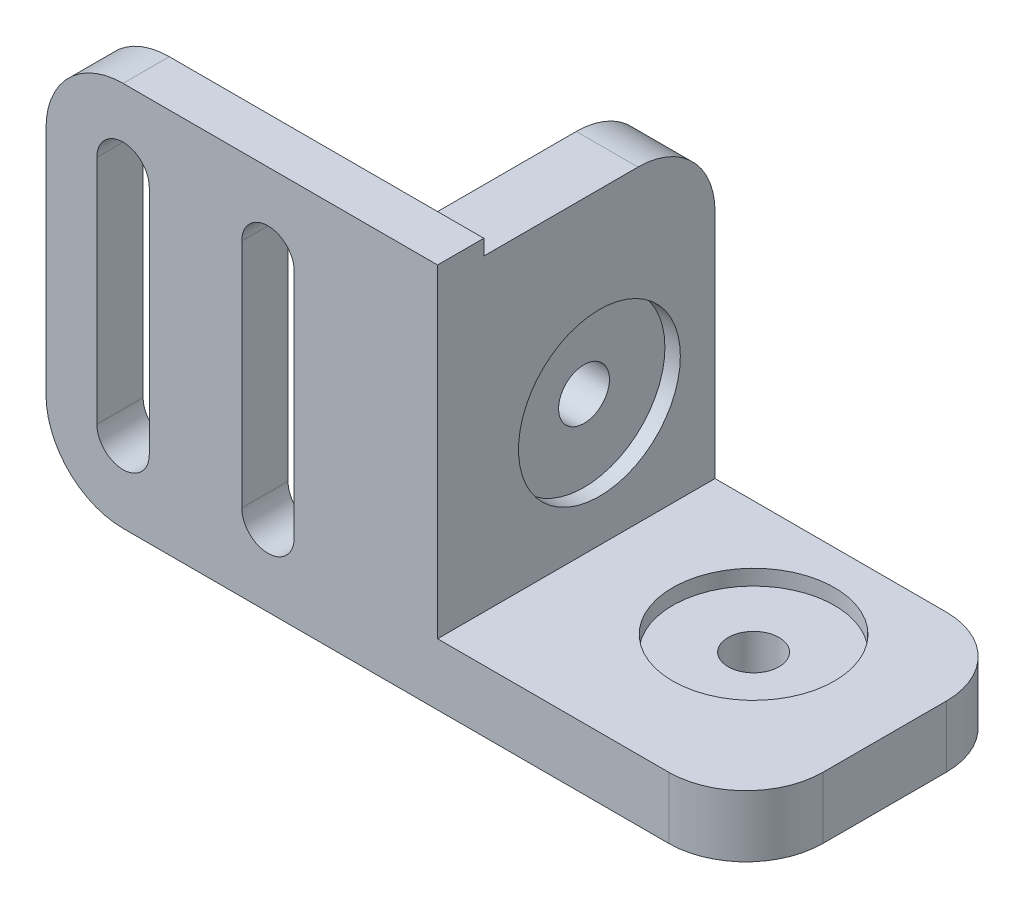
from build123d import *

# Parameters (mm, degrees)
RESSALTO_EXTRUS_O2_DEPTH   = 15
ESBO_O4_R                  = 1.65
CORTE_EXTRUS_O1_DEPTH      = 1
CORTE_EXTRUS_O1_DEPTH_BACK = 25
ESBO_O5_R                  = 1.65
CORTE_EXTRUS_O2_DEPTH      = 15
ESBO_O6_R                  = 5.25
CORTE_EXTRUS_O3_DEPTH      = 1
ESBO_O7_R                  = 5.25
CORTE_EXTRUS_O4_DEPTH      = 1
RESSALTO_EXTRUS_O3_DEPTH   = 3
FILETE1_R                  = 5


with BuildPart() as part:
    # Esboço2 → Ressalto-extrusão2 (new body)
    with BuildSketch(Plane.XY):
        Polygon((0, 0), (20, 0), (20, -4), (-4, -4), (-4, 20), (0, 20), align=None)
    extrude(amount=RESSALTO_EXTRUS_O2_DEPTH)

    # Esboço4 → Corte-extrusão1 (cut, two sides)
    with BuildSketch(Plane.ZY.offset(4)) as corte_extrus_o1_sk:
        with Locations((7.5, 8)):
            Circle(ESBO_O4_R)
    extrude(amount=CORTE_EXTRUS_O1_DEPTH, mode=Mode.SUBTRACT)
    extrude(corte_extrus_o1_sk.sketch, amount=-CORTE_EXTRUS_O1_DEPTH_BACK, mode=Mode.SUBTRACT)

    # Esboço5 → Corte-extrusão2 (cut)
    with BuildSketch(Plane(origin=(0, 0, 0), x_dir=(1, 0, 0), z_dir=(0, 1, 0))):
        with Locations((10, -7.5)):
            Circle(ESBO_O5_R)
    extrude(amount=-CORTE_EXTRUS_O2_DEPTH, mode=Mode.SUBTRACT)

    # Esboço6 → Corte-extrusão3 (cut)
    with BuildSketch(Plane(origin=(0, 0, 0), x_dir=(1, 0, 0), z_dir=(0, 1, 0))):
        with Locations((10, -7.5)):
            Circle(ESBO_O6_R)
    extrude(amount=-CORTE_EXTRUS_O3_DEPTH, mode=Mode.SUBTRACT)

    # Esboço7 → Corte-extrusão4 (cut)
    with BuildSketch(Plane(origin=(0, 0, 0), x_dir=(0, 0, -1), z_dir=(1, 0, 0))):
        with Locations((-7.5, 8)):
            Circle(ESBO_O7_R)
    extrude(amount=-CORTE_EXTRUS_O4_DEPTH, mode=Mode.SUBTRACT)

    # Esboço9 → Ressalto-extrusão3 (add)
    with BuildSketch(Plane.XY.offset(15)):
        Polygon((20, -4), (-25.4, -4), (-25.4, 21), (0, 21), (0, 0), (20, 0), align=None)
        with BuildLine():
            Line((-22.1, 16), (-22.1, 1))
            ThreePointArc((-22.1, 1), (-20.4, -0.7), (-18.7, 1))
            Line((-18.7, 1), (-18.7, 16))
            ThreePointArc((-18.7, 16), (-20.4, 17.7), (-22.1, 16))
        make_face(mode=Mode.SUBTRACT)
        with BuildLine():
            Line((-9.3, 1), (-9.3, 16))
            ThreePointArc((-9.3, 16), (-11, 17.7), (-12.7, 16))
            Line((-12.7, 16), (-12.7, 1))
            ThreePointArc((-12.7, 1), (-11, -0.7), (-9.3, 1))
        make_face(mode=Mode.SUBTRACT)
    extrude(amount=RESSALTO_EXTRUS_O3_DEPTH)

    # Filete1
    filete1_edges = [part.edges().sort_by_distance(p)[0] for p in [
        (20, -2, 18),
        (-25.4, 21, 16.5),
        (-25.4, -4, 16.5),
        (20, -2, 0),
        (-2, 20, 0),
    ]]
    fillet(filete1_edges, radius=FILETE1_R)


solid = part.part
